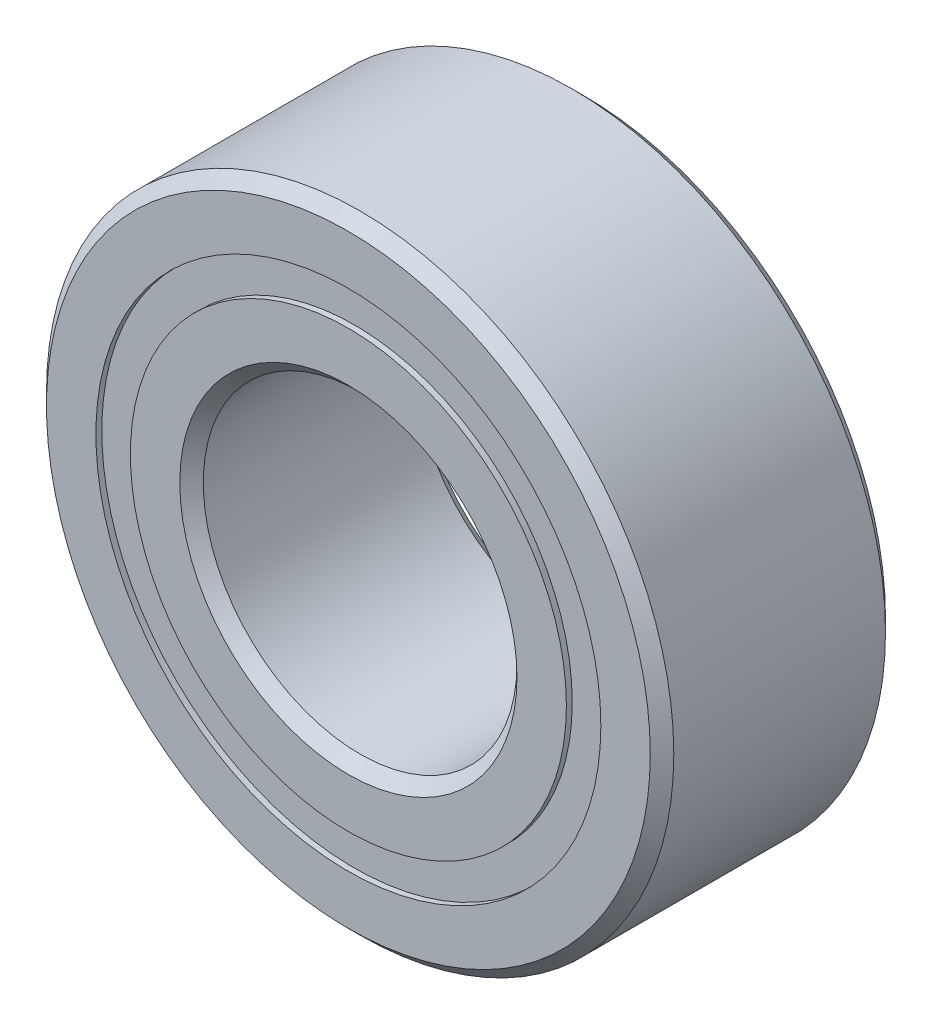
from build123d import *

# Parameters (mm, degrees)
CIRPATTERN1_COUNT = 12
SKETCH6_W         = 1.147826059
SKETCH6_H         = 0.697802198


with BuildPart() as part:
    # Sketch1 → Revolve1 (revolve)
    with BuildSketch(Plane(origin=(0, 0, 0), x_dir=(0, 0, -1), z_dir=(1, 0, 0))):
        with BuildLine():
            Line((2.143125, 6.35), (-2.143125, 6.35))
            Line((-2.143125, 6.35), (-2.38125, 6.111875))
            Line((-2.38125, 6.111875), (-2.38125, 5.111401099))
            Line((-2.38125, 5.111401099), (-1.058333333, 5.111401099))
            ThreePointArc((-1.058333333, 5.111401099), (0, 5.876861441), (1.058333333, 5.111401099))
            Line((1.058333333, 5.111401099), (2.38125, 5.111401099))
            Line((2.38125, 5.111401099), (2.38125, 6.111875))
            Line((2.38125, 6.111875), (2.143125, 6.35))
        make_face()
    revolve(axis=Axis((0, 0, 2.38125), (0, 0, -1)))


with BuildPart() as body_2:
    # Sketch3 → Revolve3 (revolve)
    with BuildSketch(Plane(origin=(0, 0, 0), x_dir=(0, 0, -1), z_dir=(1, 0, 0))):
        with BuildLine():
            Line((-2.38125, 4.413598901), (-1.058333333, 4.413598901))
            ThreePointArc((-1.058333333, 4.413598901), (0, 3.648138559), (1.058333333, 4.413598901))
            Line((1.058333333, 4.413598901), (2.38125, 4.413598901))
            Line((2.38125, 4.413598901), (2.38125, 3.413125))
            Line((2.38125, 3.413125), (2.143125, 3.175))
            Line((2.143125, 3.175), (-2.143125, 3.175))
            Line((-2.143125, 3.175), (-2.38125, 3.413125))
            Line((-2.38125, 3.413125), (-2.38125, 4.413598901))
        make_face()
    revolve(axis=Axis((0, 0, 2.38125), (0, 0, -1)))


with BuildPart() as body_3:
    # Sketch4 → Revolve4 (revolve)
    with BuildSketch(Plane(origin=(0, 0, 0), x_dir=(0, 0, -1), z_dir=(1, 0, 0))):
        with BuildLine():
            Line((-1.114361441, 4.7625), (1.114361441, 4.7625))
            ThreePointArc((1.114361441, 4.7625), (0, 5.876861441), (-1.114361441, 4.7625))
        make_face()
    revolve(axis=Axis((0, 4.7625, 1.114361441), (0, 0, -1)))


with BuildPart() as cirpattern1_1:
    # CirPattern1: pattern copy
    add(body_3.part.rotate(Axis((0, 0, -2.38125), (0, 0, 1)), 1 * 360 / CIRPATTERN1_COUNT))


with BuildPart() as cirpattern1_2:
    # CirPattern1: pattern copy
    add(body_3.part.rotate(Axis((0, 0, -2.38125), (0, 0, 1)), 2 * 360 / CIRPATTERN1_COUNT))


with BuildPart() as cirpattern1_3:
    # CirPattern1: pattern copy
    add(body_3.part.rotate(Axis((0, 0, -2.38125), (0, 0, 1)), 3 * 360 / CIRPATTERN1_COUNT))


with BuildPart() as cirpattern1_4:
    # CirPattern1: pattern copy
    add(body_3.part.rotate(Axis((0, 0, -2.38125), (0, 0, 1)), 4 * 360 / CIRPATTERN1_COUNT))


with BuildPart() as cirpattern1_5:
    # CirPattern1: pattern copy
    add(body_3.part.rotate(Axis((0, 0, -2.38125), (0, 0, 1)), 5 * 360 / CIRPATTERN1_COUNT))


with BuildPart() as cirpattern1_6:
    # CirPattern1: pattern copy
    add(body_3.part.rotate(Axis((0, 0, -2.38125), (0, 0, 1)), 6 * 360 / CIRPATTERN1_COUNT))


with BuildPart() as cirpattern1_7:
    # CirPattern1: pattern copy
    add(body_3.part.rotate(Axis((0, 0, -2.38125), (0, 0, 1)), 7 * 360 / CIRPATTERN1_COUNT))


with BuildPart() as cirpattern1_8:
    # CirPattern1: pattern copy
    add(body_3.part.rotate(Axis((0, 0, -2.38125), (0, 0, 1)), 8 * 360 / CIRPATTERN1_COUNT))


with BuildPart() as cirpattern1_9:
    # CirPattern1: pattern copy
    add(body_3.part.rotate(Axis((0, 0, -2.38125), (0, 0, 1)), 9 * 360 / CIRPATTERN1_COUNT))


with BuildPart() as cirpattern1_10:
    # CirPattern1: pattern copy
    add(body_3.part.rotate(Axis((0, 0, -2.38125), (0, 0, 1)), 10 * 360 / CIRPATTERN1_COUNT))


with BuildPart() as cirpattern1_11:
    # CirPattern1: pattern copy
    add(body_3.part.rotate(Axis((0, 0, -2.38125), (0, 0, 1)), 11 * 360 / CIRPATTERN1_COUNT))


with BuildPart() as body_15:
    # Sketch6 → Revolve5 (revolve)
    with BuildSketch(Plane(origin=(0, 0, 0), x_dir=(0, 0, -1), z_dir=(1, 0, 0))):
        with Locations((-1.688274471, 4.7625)):
            Rectangle(SKETCH6_W, SKETCH6_H)
        with Locations((1.688274471, 4.7625)):
            Rectangle(SKETCH6_W, SKETCH6_H)
    revolve(axis=Axis((0, 0, 2.38125), (0, 0, -1)))


solid = Compound([part.part, body_2.part, body_3.part, cirpattern1_1.part, cirpattern1_2.part, cirpattern1_3.part, cirpattern1_4.part, cirpattern1_5.part, cirpattern1_6.part, cirpattern1_7.part, cirpattern1_8.part, cirpattern1_9.part, cirpattern1_10.part, cirpattern1_11.part, body_15.part])
